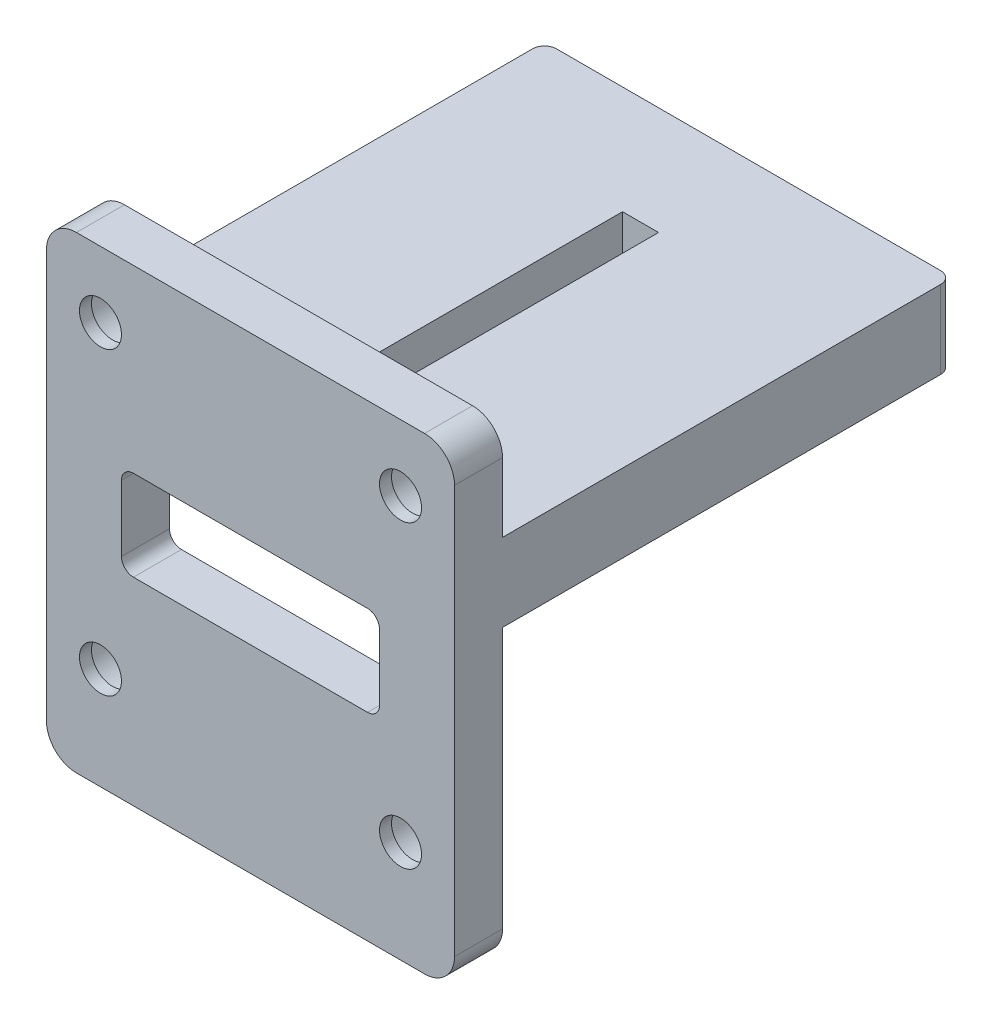
from build123d import *

# Parameters (mm, degrees)
SKETCH1_W           = 68
SKETCH1_H           = 78
BOSS_EXTRUDE1_DEPTH = 8
BOSS_EXTRUDE2_DEPTH = 75
CUT_EXTRUDE1_REACH  = 85
SKETCH3_W           = 43
SKETCH3_H           = 15
FILLET1_R           = 2
FILLET2_R           = 5
SKETCH4_W           = 6
SKETCH4_H           = 45
CUT_EXTRUDE2_DEPTH  = 62.5
SKETCH5_R           = 3.5
CUT_EXTRUDE3_DEPTH  = 9
SKETCH7_R           = 5.5
CUT_EXTRUDE4_DEPTH  = 6


with BuildPart() as part:
    # Sketch1 → Boss-Extrude1 (new body)
    with BuildSketch(Plane.XY):
        Rectangle(SKETCH1_W, SKETCH1_H)
    extrude(amount=BOSS_EXTRUDE1_DEPTH)

    # Sketch2 → Boss-Extrude2 (add)
    with BuildSketch(Plane(origin=(0, 0, 0), x_dir=(-1, 0, 0), z_dir=(0, 0, -1))):
        Polygon((-34, 22.5), (34, 22.5), (34, 9.5), (19.5, 9.5), (19.5, 15.5), (-19.5, 15.5), (-19.5, 9.5), (-34, 9.5), align=None)
    extrude(amount=BOSS_EXTRUDE2_DEPTH)

    # Sketch3 → Cut-Extrude1 (cut, up to next)
    with BuildSketch(Plane.XY.offset(8), mode=Mode.PRIVATE) as cut_extrude1_sk1:
        with Locations((0, 1.5)):
            Rectangle(SKETCH3_W, SKETCH3_H)
    cut_extrude1_tool1 = extrude(cut_extrude1_sk1.sketch, amount=-CUT_EXTRUDE1_REACH, mode=Mode.PRIVATE) & part.part
    add(cut_extrude1_tool1.solids().sort_by_distance((0, 1.5, 8))[0], mode=Mode.SUBTRACT)

    # Fillet1
    fillet1_edges = [part.edges().sort_by_distance(p)[0] for p in [
        (34, 16, -75),
        (-34, 16, -75),
        (-21.5, -6, 4),
        (-21.5, 9, 4),
        (21.5, 9, 4),
        (21.5, -6, 4),
    ]]
    fillet(fillet1_edges, radius=FILLET1_R)

    # Fillet2
    fillet2_edges = [part.edges().sort_by_distance(p)[0] for p in [
        (34, -39, 4),
        (-34, -39, 4),
        (-34, 39, 4),
        (34, 39, 4),
    ]]
    fillet(fillet2_edges, radius=FILLET2_R)

    # Sketch4 → Cut-Extrude2 (cut, through all)
    with BuildSketch(Plane(origin=(0, 22.5, 0), x_dir=(1, 0, 0), z_dir=(0, 1, 0))):
        with Locations((0, 34.5)):
            Rectangle(SKETCH4_W, SKETCH4_H)
    extrude(amount=-CUT_EXTRUDE2_DEPTH, mode=Mode.SUBTRACT)

    # Sketch5 → Cut-Extrude3 (cut, through all)
    with BuildSketch(Plane(origin=(0, 0, 0), x_dir=(-1, 0, 0), z_dir=(0, 0, -1))):
        with Locations((-25, 28)):
            Circle(SKETCH5_R)
        with Locations((25, 28)):
            Circle(SKETCH5_R)
        with Locations((-25, -22)):
            Circle(SKETCH5_R)
        with Locations((25, -22)):
            Circle(SKETCH5_R)
    extrude(amount=-CUT_EXTRUDE3_DEPTH, mode=Mode.SUBTRACT)

    # Sketch7 → Cut-Extrude4 (cut)
    with BuildSketch(Plane(origin=(0, 0, 0), x_dir=(-1, 0, 0), z_dir=(0, 0, -1))):
        with Locations((-25, 28)):
            Circle(SKETCH7_R)
        with Locations((25, 28)):
            Circle(SKETCH7_R)
        with Locations((-25, -22)):
            Circle(SKETCH7_R)
        with Locations((25, -22)):
            Circle(SKETCH7_R)
    extrude(amount=-CUT_EXTRUDE4_DEPTH, mode=Mode.SUBTRACT)


solid = part.part
